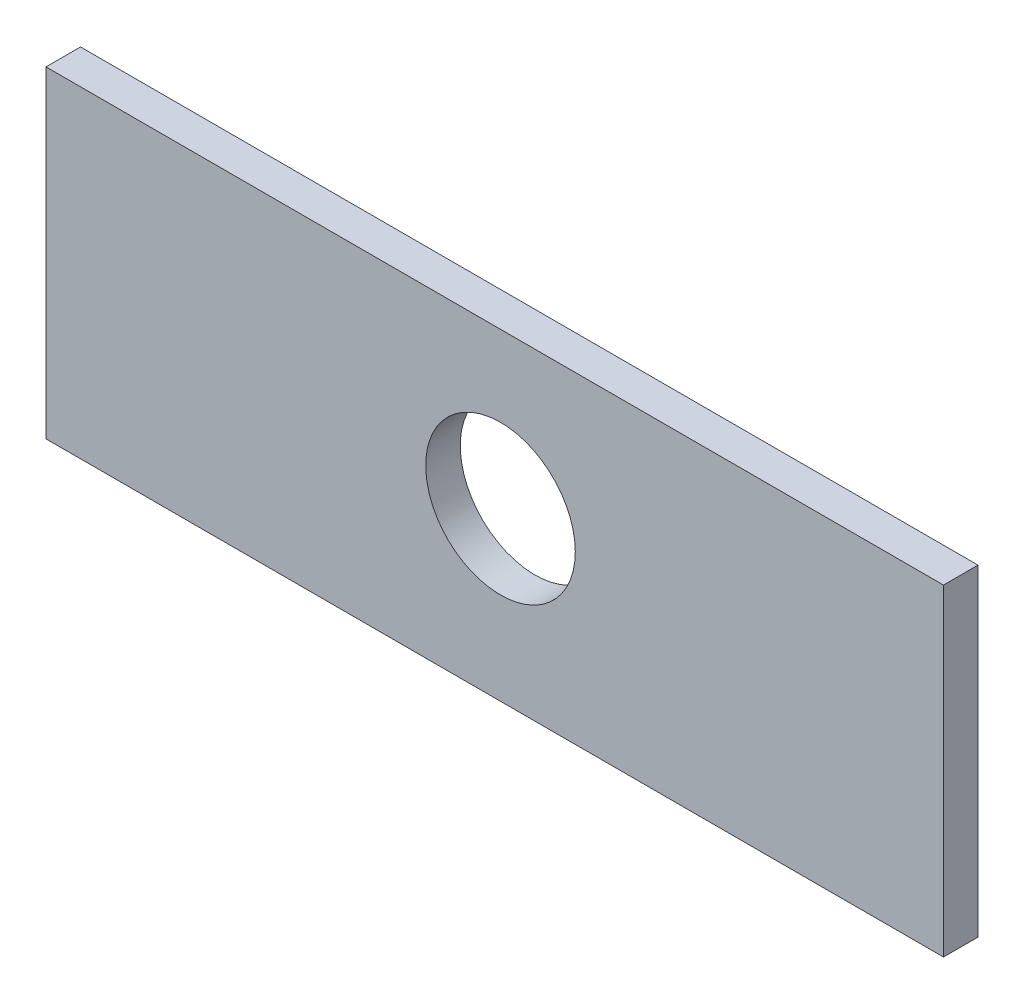
from build123d import *

# Parameters (mm, degrees)
SKETCH1_W           = 78
SKETCH1_H           = 28
SKETCH1_R           = 6.5
BOSS_EXTRUDE1_DEPTH = 1.5


with BuildPart() as part:
    # Sketch1 → Boss-Extrude1 (new body, symmetric)
    with BuildSketch(Plane.XY):
        with Locations((-5.192923333, -4.997384861)):
            Rectangle(SKETCH1_W, SKETCH1_H)
        with Locations((-4.692923333, -4.497384861)):
            Circle(SKETCH1_R, mode=Mode.SUBTRACT)
    extrude(amount=BOSS_EXTRUDE1_DEPTH, both=True)


solid = part.part
